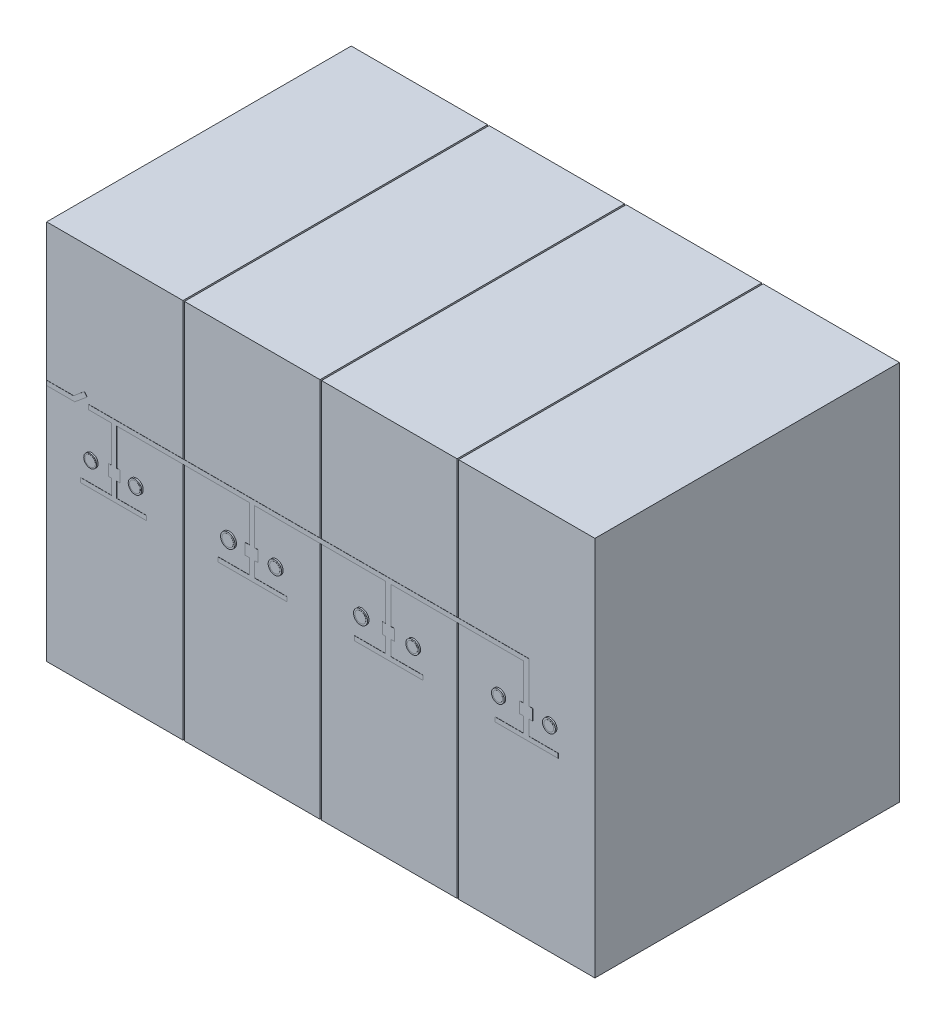
from build123d import *

# Parameters (mm, degrees)
CROQUIS1_W              = 3600
CROQUIS1_H              = 2500
SALIENTE_EXTRUIR1_DEPTH = 2000
CROQUIS3_W              = 10
CROQUIS3_H              = 2500
CORTAR_EXTRUIR1_DEPTH   = 2000
SALIENTE_EXTRUIR2_DEPTH = 1
CROQUIS5_R              = 42.042349856
CROQUIS5_R_2            = 44.227433636
CROQUIS5_R_3            = 47.161857107
CROQUIS5_R_4            = 43.965695281
CROQUIS5_R_5            = 45.833892846
CROQUIS5_R_6            = 43.568215229
CROQUIS5_R_7            = 41.81955042
CROQUIS5_R_8            = 42.411091006
SALIENTE_EXTRUIR3_DEPTH = 10
CROQUIS6_R              = 34.529979584
CROQUIS6_R_2            = 35.138962303
CROQUIS6_R_3            = 37.079078028
CROQUIS6_R_4            = 33.421162006
CROQUIS6_R_5            = 35.597607771
CROQUIS6_R_6            = 33.918842717
CROQUIS6_R_7            = 31.90982207
CROQUIS6_R_8            = 31.631714901
SALIENTE_EXTRUIR4_DEPTH = 0.5


with BuildPart() as part:
    # Croquis1 → Saliente-Extruir1 (new body)
    with BuildSketch(Plane.XY):
        with Locations((1800, 1250)):
            Rectangle(CROQUIS1_W, CROQUIS1_H)
    extrude(amount=SALIENTE_EXTRUIR1_DEPTH)

    # Croquis3 → Cortar-Extruir1 (cut)
    with BuildSketch(Plane.XY.offset(2000)):
        with Locations((900, 1250)):
            Rectangle(CROQUIS3_W, CROQUIS3_H)
        with Locations((1800, 1250)):
            Rectangle(CROQUIS3_W, CROQUIS3_H)
        with Locations((2700, 1250)):
            Rectangle(CROQUIS3_W, CROQUIS3_H)
    extrude(amount=-CORTAR_EXTRUIR1_DEPTH, mode=Mode.SUBTRACT)

    # Croquis4 → Saliente-Extruir2 (add)
    with BuildSketch(Plane.XY.offset(2000)):
        Polygon((0, 1600), (177.131722561, 1600), (248.433073904, 1659.612953528), (266.737801234, 1637.719191898), (221.622952956, 1600), (185.740809669, 1570), (0, 1570), align=None)
        Polygon((2262.67056397, 1570), (3131.321237056, 1570), (3131.321237056, 1329.696449822), (3105.870170693, 1329.696449822), (3105.870170693, 1256.885113309), (3131.321237056, 1256.885113309), (3131.321237056, 1158.262993453), (2943.521251595, 1158.262993453), (2943.521251595, 1129.2585574), (3359.702855334, 1129.2585574), (3359.702855334, 1158.262993453), (3168.197091237, 1158.262993453), (3168.197091237, 1256.885113309), (3192.727563387, 1256.885113309), (3192.727563387, 1329.696449822), (3168.197091237, 1329.696449822), (3168.197091237, 1570), (3168.197091237, 1600), (274.19742775, 1600), (274.19742775, 1570), (428.091552217, 1570), (428.091552217, 1329.696449822), (407.889246887, 1329.696449822), (407.889246887, 1256.885113309), (428.091552217, 1256.885113309), (428.091552217, 1158.262993453), (221.622952956, 1158.262993453), (221.622952956, 1129.2585574), (655.534740684, 1129.2585574), (655.534740684, 1158.262993453), (460.255695781, 1158.262993453), (460.255695781, 1256.885113309), (483.087840335, 1256.885113309), (483.087840335, 1329.696449822), (460.255695781, 1329.696449822), (460.255695781, 1570), (1331.979926835, 1570), (1331.979926835, 1329.696449822), (1304.880988731, 1329.696449822), (1304.880988731, 1256.885113309), (1331.979926835, 1256.885113309), (1331.979926835, 1158.262993453), (1126.823452844, 1158.262993453), (1126.823452844, 1129.2585574), (1577.800681664, 1129.2585574), (1577.800681664, 1158.262993453), (1364.876608308, 1158.262993453), (1364.876608308, 1256.885113309), (1388.842422483, 1256.885113309), (1388.842422483, 1329.696449822), (1364.876608308, 1329.696449822), (1364.876608308, 1570), (2226.641720181, 1570), (2226.641720181, 1329.696449822), (2206.83575822, 1329.696449822), (2206.83575822, 1256.885113309), (2226.641720181, 1256.885113309), (2226.641720181, 1158.262993453), (2021.178837256, 1158.262993453), (2021.178837256, 1129.2585574), (2472.729026323, 1129.2585574), (2472.729026323, 1158.262993453), (2262.67056397, 1158.262993453), (2262.67056397, 1256.885113309), (2284.098867396, 1256.885113309), (2284.098867396, 1329.696449822), (2262.67056397, 1329.696449822), align=None)
    extrude(amount=SALIENTE_EXTRUIR2_DEPTH)

    # Croquis5 → Saliente-Extruir3 (add)
    with BuildSketch(Plane.XY.offset(2000)):
        with Locations((295.435400679, 1293.290781566)):
            Circle(CROQUIS5_R)
        with Locations((589.830635079, 1293.290781566)):
            Circle(CROQUIS5_R_2)
        with Locations((1199.09009137, 1293.290781566)):
            Circle(CROQUIS5_R_3)
        with Locations((1508.461031639, 1293.290781566)):
            Circle(CROQUIS5_R_4)
        with Locations((2070.755084005, 1293.290781566)):
            Circle(CROQUIS5_R_5)
        with Locations((2411.685220759, 1293.290781566)):
            Circle(CROQUIS5_R_6)
        with Locations((2972.227319814, 1293.290781566)):
            Circle(CROQUIS5_R_7)
        with Locations((3307.906835958, 1293.290781566)):
            Circle(CROQUIS5_R_8)
    extrude(amount=SALIENTE_EXTRUIR3_DEPTH)

    # Croquis6 → Saliente-Extruir4 (add)
    with BuildSketch(Plane.XY.offset(2010)):
        with Locations((295.435400679, 1293.290781566)):
            Circle(CROQUIS6_R)
        with Locations((589.830635079, 1293.290781566)):
            Circle(CROQUIS6_R_2)
        with Locations((1199.09009137, 1293.290781566)):
            Circle(CROQUIS6_R_3)
        with Locations((1508.461031639, 1293.290781566)):
            Circle(CROQUIS6_R_4)
        with Locations((2070.755084005, 1293.290781566)):
            Circle(CROQUIS6_R_5)
        with Locations((2411.685220759, 1293.290781566)):
            Circle(CROQUIS6_R_6)
        with Locations((2972.227319814, 1293.290781566)):
            Circle(CROQUIS6_R_7)
        with Locations((3307.906835958, 1293.290781566)):
            Circle(CROQUIS6_R_8)
    extrude(amount=SALIENTE_EXTRUIR4_DEPTH)


solid = part.part
